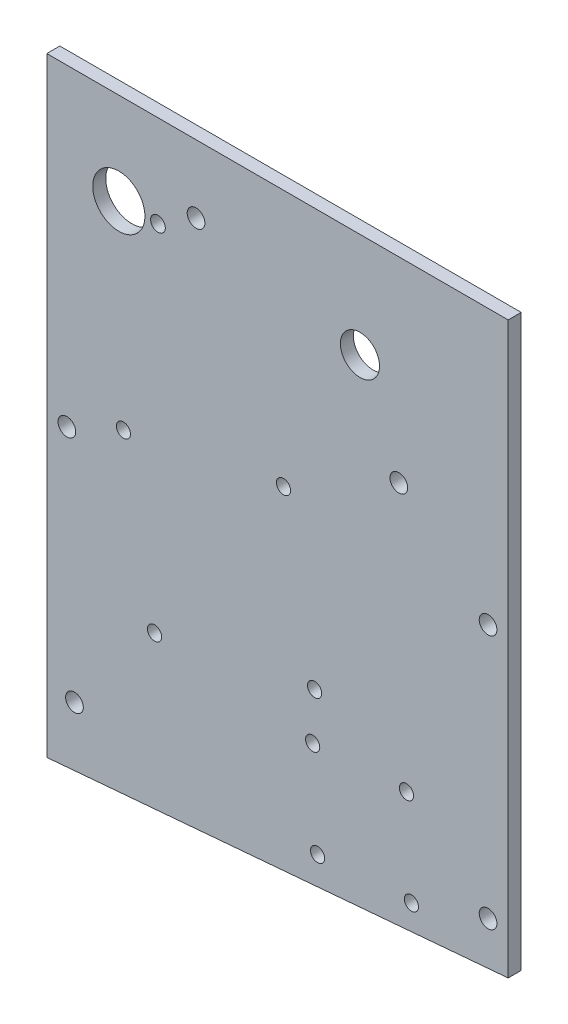
from build123d import *

# Parameters (mm, degrees)
BOSS_EXTRUDE1_DEPTH             = 3.175
F_6_CLEARANCE_HOLE1_D           = 4.3053
F_4_CLEARANCE_HOLE1_D           = 3.4544
F_6_CLEARANCE_HOLE2_D           = 4.3053
F_9_64_0_14063_DIAMETER_HOLE1_D = 3.572002
F_3_8_0_375_DIAMETER_HOLE1_D    = 9.525
F_1_2_0_5_DIAMETER_HOLE1_D      = 12.7


with BuildPart() as part:
    # Sketch1 → Boss-Extrude1 (new body)
    with BuildSketch(Plane.XY):
        Polygon((112.268, 0), (0, 0), (0, -148.336), (112.268, -138.684), align=None)
    extrude(amount=-BOSS_EXTRUDE1_DEPTH)

    # #6 Clearance Hole1 (through all)
    with Locations(Plane.XY):
        with Locations((6.731, -133.35), (107.3785, -128.5875), (107.3785, -66.675), (4.8895, -76.2)):
            Hole(F_6_CLEARANCE_HOLE1_D / 2)

    # #4 Clearance Hole1 (through all)
    with Locations(Plane.XY):
        with Locations((18.644469576, -70.03220158), (57.60279842, -62.459469576), (65.175530424, -101.41779842), (26.21720158, -108.990530424), (65.891864398, -135.837535562), (88.720535562, -134.641135602), (87.524135602, -111.812464438), (64.695464438, -113.008864398)):
            Hole(F_4_CLEARANCE_HOLE1_D / 2)

    # #6 Clearance Hole2 (through all)
    with Locations(Plane.XY):
        with Locations((36.322, -16.51), (85.6615, -47.625)):
            Hole(F_6_CLEARANCE_HOLE2_D / 2)

    # 9/64 (0.14063) Diameter Hole1 (through all)
    with Locations(Plane.XY):
        with Locations((27.051, -22.352)):
            Hole(F_9_64_0_14063_DIAMETER_HOLE1_D / 2)

    # 3/8 (0.375) Diameter Hole1 (through all)
    with Locations(Plane.XY):
        with Locations((76.2, -25.4)):
            Hole(F_3_8_0_375_DIAMETER_HOLE1_D / 2)

    # 1/2 (0.5) Diameter Hole1 (through all)
    with Locations(Plane.XY):
        with Locations((17.526, -22.352)):
            Hole(F_1_2_0_5_DIAMETER_HOLE1_D / 2)


solid = part.part
